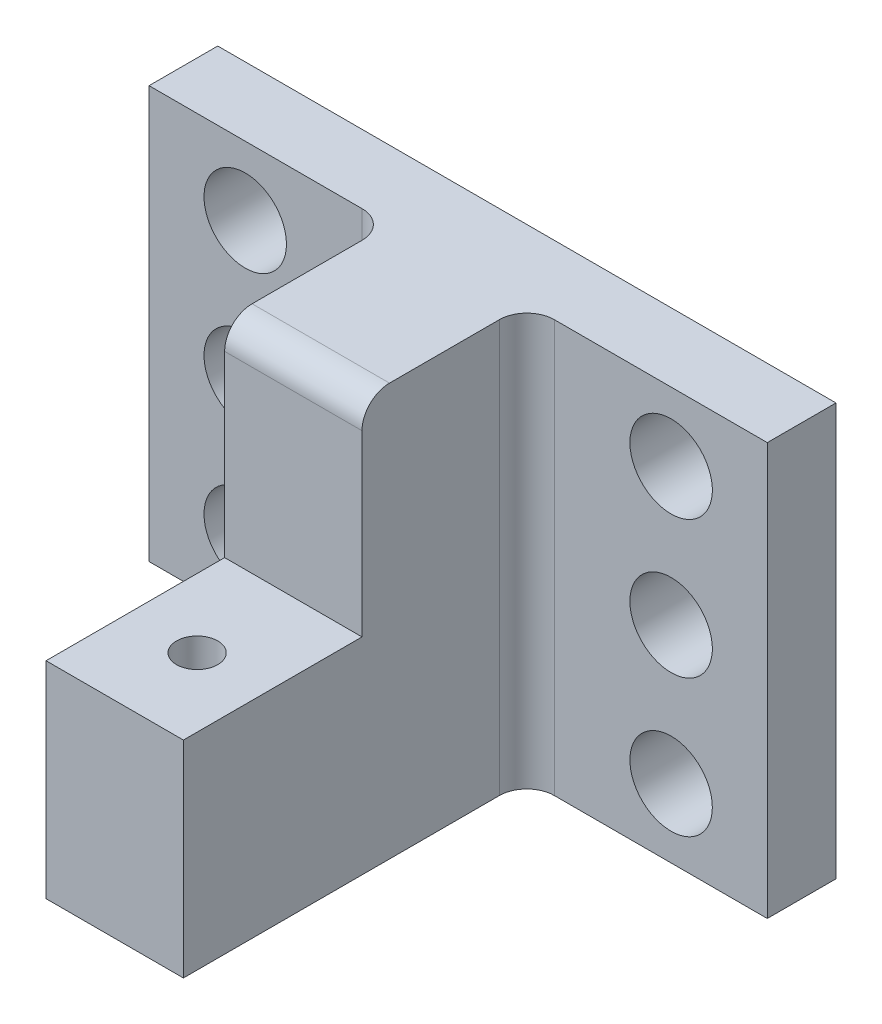
from build123d import *

# Parameters (mm, degrees)
SKETCH1_W           = 45
SKETCH1_H           = 30
BASE_DEPTH          = 5
SKETCH2_W           = 10
SKETCH2_H           = 30
BOSS_EXTRUDE2_DEPTH = 25
SKETCH5_R           = 1.5
CABLE_HOLE_DEPTH    = 15
SKETCH9_R           = 3
SCREW_DEPTH         = 5
SKETCH10_W          = 15
SKETCH10_H          = 20
CUT_EXTRUDE8_DEPTH  = 10
FILLET5_R           = 2
FILLET6_R           = 2
FILLET7_R           = 2


with BuildPart() as part:
    # Sketch1 → Base (new body)
    with BuildSketch(Plane.XY):
        Rectangle(SKETCH1_W, SKETCH1_H)
    extrude(amount=BASE_DEPTH)

    # Sketch2 → Boss-Extrude2 (add)
    with BuildSketch(Plane.XY.offset(5)):
        Rectangle(SKETCH2_W, SKETCH2_H)
    extrude(amount=BOSS_EXTRUDE2_DEPTH)

    # Sketch5 → Cable hole (cut)
    with BuildSketch(Plane.XZ.offset(15)):
        with Locations((0, 24)):
            Circle(SKETCH5_R)
    extrude(amount=-CABLE_HOLE_DEPTH, mode=Mode.SUBTRACT)

    # Sketch9 → Screw (cut)
    with BuildSketch(Plane.XY.offset(5)):
        with Locations((-15.5, 10)):
            Circle(SKETCH9_R)
        with Locations((-15.5, 0)):
            Circle(SKETCH9_R)
        with Locations((-15.5, -10)):
            Circle(SKETCH9_R)
        with Locations((15.5, -10)):
            Circle(SKETCH9_R)
        with Locations((15.5, 0)):
            Circle(SKETCH9_R)
        with Locations((15.5, 10)):
            Circle(SKETCH9_R)
    extrude(amount=-SCREW_DEPTH, mode=Mode.SUBTRACT)

    # Sketch10 → Cut-Extrude8 (cut)
    with BuildSketch(Plane.ZY.offset(5)):
        with Locations((24.5, 10)):
            Rectangle(SKETCH10_W, SKETCH10_H)
    extrude(amount=-CUT_EXTRUDE8_DEPTH, mode=Mode.SUBTRACT)

    # Fillet5
    fillet5_edges = [part.edges().sort_by_distance(p)[0] for p in [
        (0, 15, 17),
    ]]
    fillet(fillet5_edges, radius=FILLET5_R)

    # Fillet6
    fillet6_edges = [part.edges().sort_by_distance(p)[0] for p in [
        (-5, 0, 5),
    ]]
    fillet(fillet6_edges, radius=FILLET6_R)

    # Fillet7
    fillet7_edges = [part.edges().sort_by_distance(p)[0] for p in [
        (5, 0, 5),
    ]]
    fillet(fillet7_edges, radius=FILLET7_R)


solid = part.part
